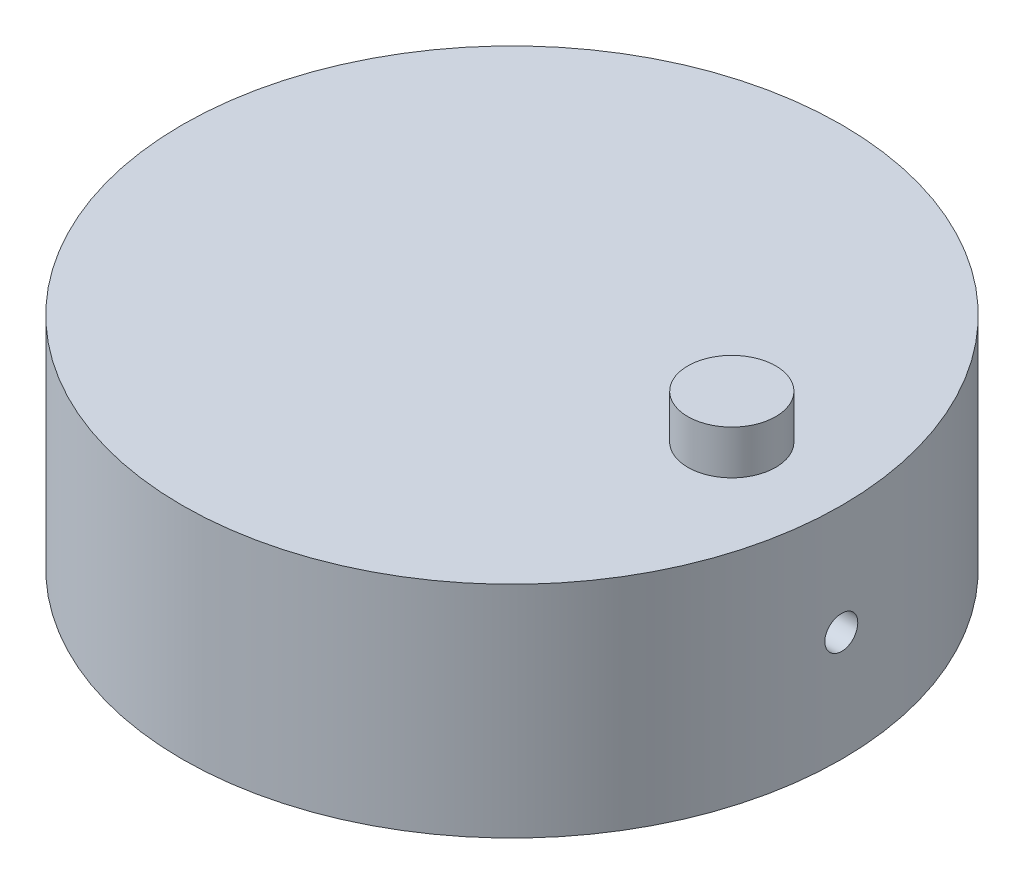
from build123d import *

# Parameters (mm, degrees)
SKETCH1_R               = 38.1
BOSS_EXTRUDE1_DEPTH     = 25.4
SKETCH2_R               = 5.08
BOSS_EXTRUDE2_DEPTH     = 5.08
SKETCH3_R               = 1.905
CUT_EXTRUDE1_DEPTH      = 46.228
CUT_EXTRUDE1_DEPTH_BACK = 46.482


with BuildPart() as part:
    # Sketch1 → Boss-Extrude1 (new body)
    with BuildSketch(Plane(origin=(0, 0, 0), x_dir=(1, 0, 0), z_dir=(0, 1, 0))):
        Circle(SKETCH1_R)
    extrude(amount=BOSS_EXTRUDE1_DEPTH)

    # Sketch2 → Boss-Extrude2 (add)
    with BuildSketch(Plane(origin=(0, 25.4, 0), x_dir=(1, 0, 0), z_dir=(0, 1, 0))):
        with Locations((25.4, 0)):
            Circle(SKETCH2_R)
    extrude(amount=BOSS_EXTRUDE2_DEPTH)

    # Sketch3 → Cut-Extrude1 (cut, two sides)
    with BuildSketch(Plane(origin=(0, 0, 0), x_dir=(0, 0, -1), z_dir=(1, 0, 0))) as cut_extrude1_sk:
        with Locations((0, 12.7)):
            Circle(SKETCH3_R)
    extrude(amount=CUT_EXTRUDE1_DEPTH, mode=Mode.SUBTRACT)
    extrude(cut_extrude1_sk.sketch, amount=-CUT_EXTRUDE1_DEPTH_BACK, mode=Mode.SUBTRACT)


solid = part.part
